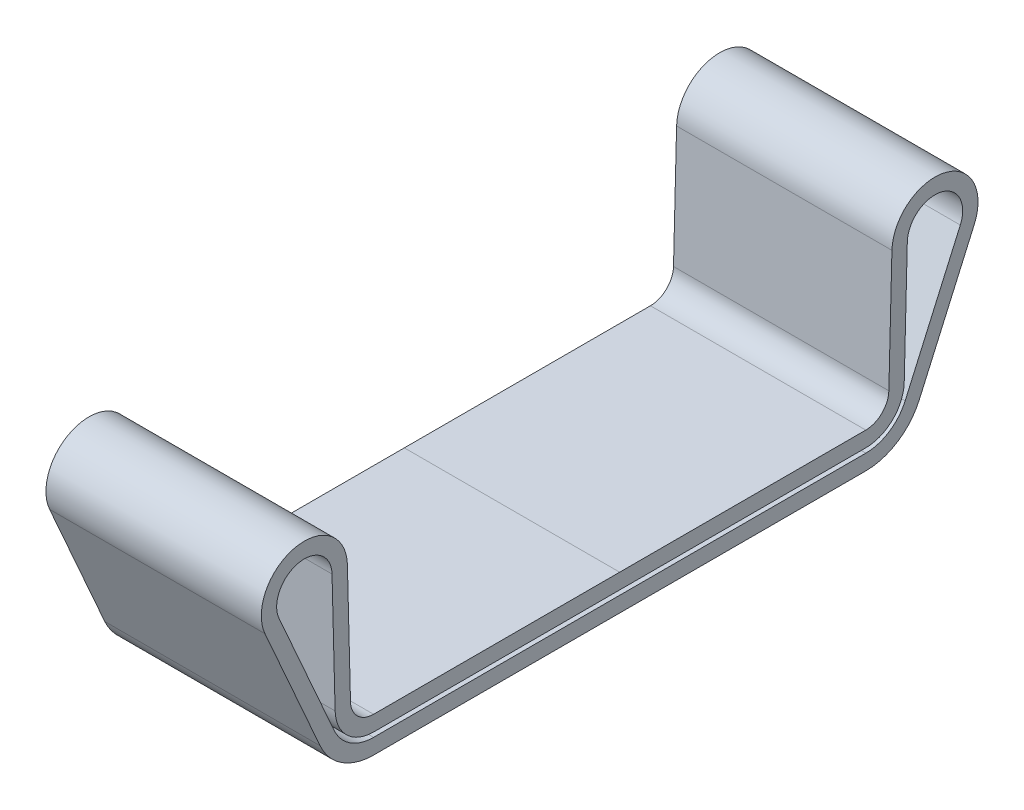
from build123d import *

# Parameters (mm, degrees)
BOSS_EXTRUDE1_DEPTH = 7


with BuildPart() as part:
    # Sketch1 → Boss-Extrude1 (new body, symmetric)
    with BuildSketch(Plane(origin=(0, 0, 0), x_dir=(0, 0, -1), z_dir=(1, 0, 0))):
        with BuildLine():
            Line((-22.14614181, 6.771839894), (-18.561151485, -1.33269977))
            ThreePointArc((-18.561151485, -1.33269977), (-17.528308744, -2.546439623), (-16.000496078, -3))
            Line((-16.000496078, -3), (0, -3))
            Line((0, -3), (0, -4))
            Line((0, -4), (-16.000496078, -4))
            ThreePointArc((-16.000496078, -4), (-18.073958177, -3.384453165), (-19.475674713, -1.737233163))
            Line((-19.475674713, -1.737233163), (-23.060665038, 6.367306501))
            ThreePointArc((-23.060665038, 6.367306501), (-21.114031535, 10.231842835), (-17.700926013, 7.572005665))
            Line((-17.700926013, 7.572005665), (-17.5, -0.238584995))
            ThreePointArc((-17.5, -0.238584995), (-17.047428938, -1.274222609), (-16.000495091, -1.700010532))
            Line((-16.000495091, -1.700010532), (0, -1.7))
            Line((0, -1.7), (0, -2.7))
            Line((0, -2.7), (-16.000494433, -2.700010532))
            ThreePointArc((-16.000494433, -2.700010532), (-17.745384177, -1.990363995), (-18.499669281, -0.264301304))
            Line((-18.499669281, -0.264301304), (-18.700595294, 7.546289356))
            ThreePointArc((-18.700595294, 7.546289356), (-20.894734558, 9.25618468), (-22.14614181, 6.771839894))
        make_face()
    boss_extrude1 = extrude(amount=BOSS_EXTRUDE1_DEPTH, both=True)

    # Mirror1: Boss-Extrude1 across plane
    add(boss_extrude1.mirror(Plane.XY))


solid = part.part
